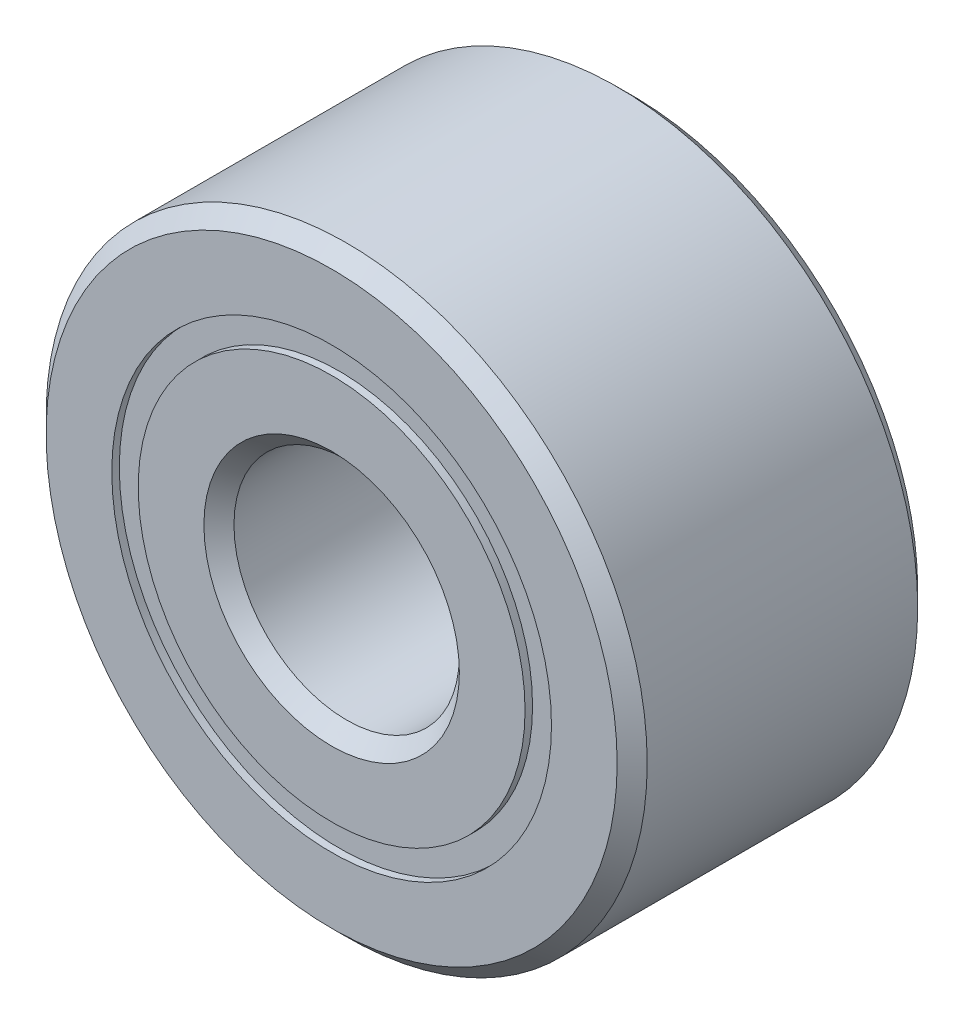
from build123d import *

# Parameters (mm, degrees)
CIRPATTERN1_COUNT = 12
SKETCH5_W         = 0.99388875
SKETCH5_H         = 0.351648352


with BuildPart() as part:
    # Sketch1 → Revolve1 (revolve)
    with BuildSketch(Plane(origin=(0, 0, 0), x_dir=(0, 0, -1), z_dir=(1, 0, 0))):
        with BuildLine():
            Line((1.8, 4), (-1.8, 4))
            Line((-1.8, 4), (-2, 3.8))
            Line((-2, 3.8), (-2, 2.925824176))
            Line((-2, 2.925824176), (-0.888888889, 2.925824176))
            ThreePointArc((-0.888888889, 2.925824176), (0, 3.65611125), (0.888888889, 2.925824176))
            Line((0.888888889, 2.925824176), (2, 2.925824176))
            Line((2, 2.925824176), (2, 3.8))
            Line((2, 3.8), (1.8, 4))
        make_face()
    revolve(axis=Axis((0, 0, 2), (0, 0, -1)))


with BuildPart() as body_2:
    # Sketch3 → Revolve3 (revolve)
    with BuildSketch(Plane(origin=(0, 0, 0), x_dir=(0, 0, -1), z_dir=(1, 0, 0))):
        with BuildLine():
            Line((-2, 2.574175824), (-0.888888889, 2.574175824))
            ThreePointArc((-0.888888889, 2.574175824), (0, 1.84388875), (0.888888889, 2.574175824))
            Line((0.888888889, 2.574175824), (2, 2.574175824))
            Line((2, 2.574175824), (2, 1.7))
            Line((2, 1.7), (1.8, 1.5))
            Line((1.8, 1.5), (-1.8, 1.5))
            Line((-1.8, 1.5), (-2, 1.7))
            Line((-2, 1.7), (-2, 2.574175824))
        make_face()
    revolve(axis=Axis((0, 0, 2), (0, 0, -1)))


with BuildPart() as body_3:
    # Sketch4 → Revolve4 (revolve)
    with BuildSketch(Plane(origin=(0, 0, 0), x_dir=(0, 0, -1), z_dir=(1, 0, 0))):
        with BuildLine():
            Line((-0.90611125, 2.75), (0.90611125, 2.75))
            ThreePointArc((0.90611125, 2.75), (0, 3.65611125), (-0.90611125, 2.75))
        make_face()
    revolve(axis=Axis((0, 2.75, 0.90611125), (0, 0, -1)))


with BuildPart() as cirpattern1_1:
    # CirPattern1: pattern copy
    add(body_3.part.rotate(Axis((0, 0, 0), (0, 0, 1)), 1 * 360 / CIRPATTERN1_COUNT))


with BuildPart() as cirpattern1_2:
    # CirPattern1: pattern copy
    add(body_3.part.rotate(Axis((0, 0, 0), (0, 0, 1)), 2 * 360 / CIRPATTERN1_COUNT))


with BuildPart() as cirpattern1_3:
    # CirPattern1: pattern copy
    add(body_3.part.rotate(Axis((0, 0, 0), (0, 0, 1)), 3 * 360 / CIRPATTERN1_COUNT))


with BuildPart() as cirpattern1_4:
    # CirPattern1: pattern copy
    add(body_3.part.rotate(Axis((0, 0, 0), (0, 0, 1)), 4 * 360 / CIRPATTERN1_COUNT))


with BuildPart() as cirpattern1_5:
    # CirPattern1: pattern copy
    add(body_3.part.rotate(Axis((0, 0, 0), (0, 0, 1)), 5 * 360 / CIRPATTERN1_COUNT))


with BuildPart() as cirpattern1_6:
    # CirPattern1: pattern copy
    add(body_3.part.rotate(Axis((0, 0, 0), (0, 0, 1)), 6 * 360 / CIRPATTERN1_COUNT))


with BuildPart() as cirpattern1_7:
    # CirPattern1: pattern copy
    add(body_3.part.rotate(Axis((0, 0, 0), (0, 0, 1)), 7 * 360 / CIRPATTERN1_COUNT))


with BuildPart() as cirpattern1_8:
    # CirPattern1: pattern copy
    add(body_3.part.rotate(Axis((0, 0, 0), (0, 0, 1)), 8 * 360 / CIRPATTERN1_COUNT))


with BuildPart() as cirpattern1_9:
    # CirPattern1: pattern copy
    add(body_3.part.rotate(Axis((0, 0, 0), (0, 0, 1)), 9 * 360 / CIRPATTERN1_COUNT))


with BuildPart() as cirpattern1_10:
    # CirPattern1: pattern copy
    add(body_3.part.rotate(Axis((0, 0, 0), (0, 0, 1)), 10 * 360 / CIRPATTERN1_COUNT))


with BuildPart() as cirpattern1_11:
    # CirPattern1: pattern copy
    add(body_3.part.rotate(Axis((0, 0, 0), (0, 0, 1)), 11 * 360 / CIRPATTERN1_COUNT))


with BuildPart() as body_15:
    # Sketch5 → Revolve5 (revolve)
    with BuildSketch(Plane(origin=(0, 0, 0), x_dir=(0, 0, -1), z_dir=(1, 0, 0))):
        with Locations((-1.403055625, 2.75)):
            Rectangle(SKETCH5_W, SKETCH5_H)
        with Locations((1.403055625, 2.75)):
            Rectangle(SKETCH5_W, SKETCH5_H)
    revolve(axis=Axis((0, 0, 2), (0, 0, -1)))


solid = Compound([part.part, body_2.part, body_3.part, cirpattern1_1.part, cirpattern1_2.part, cirpattern1_3.part, cirpattern1_4.part, cirpattern1_5.part, cirpattern1_6.part, cirpattern1_7.part, cirpattern1_8.part, cirpattern1_9.part, cirpattern1_10.part, cirpattern1_11.part, body_15.part])
